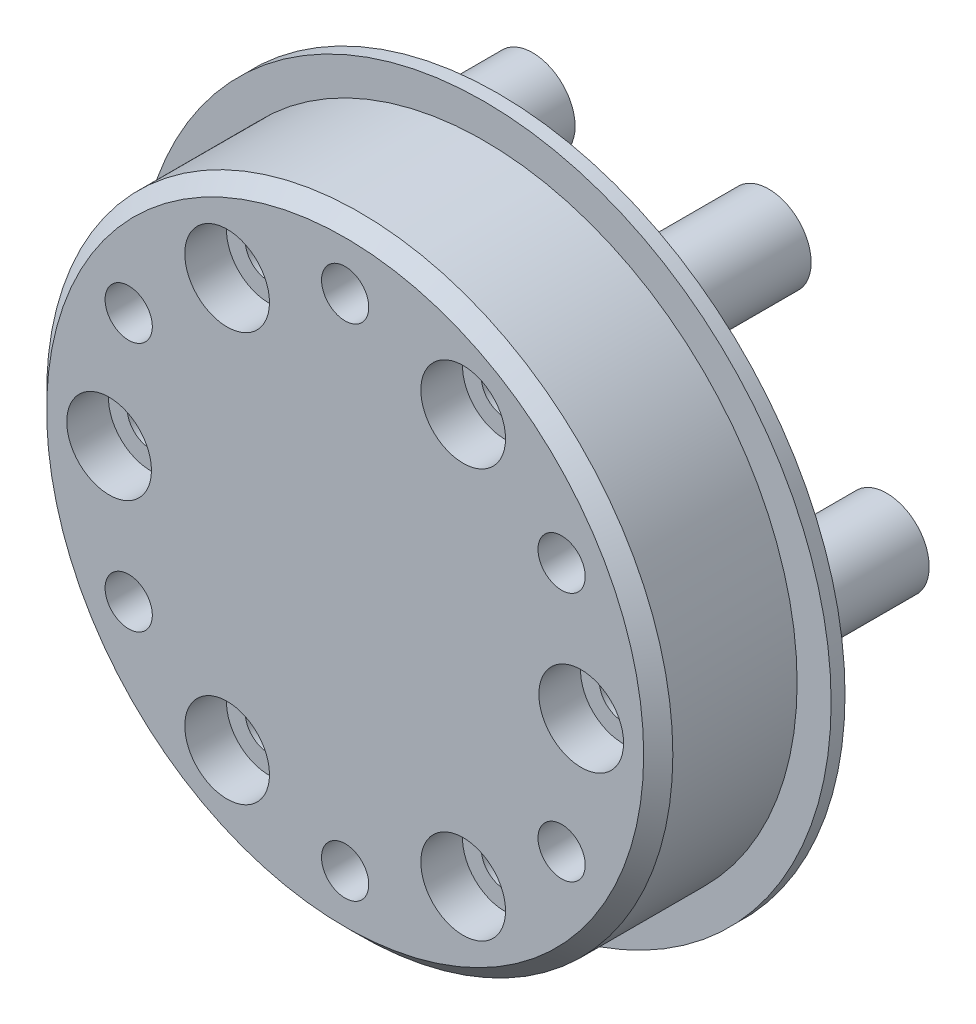
from build123d import *

# Parameters (mm, degrees)
SKETCH_1_W                   = 25
SKETCH_1_H                   = 1
SKETCH_2_R                   = 22.55
EXTRUDE_1_DEPTH              = 10
HOLE_WIZARD_M3_1_D           = 3.4
HOLE_WIZARD_M3_1_DEPTH       = 11
HOLE_WIZARD_M3_1_CBORE_D     = 4.5
HOLE_WIZARD_M3_1_CBORE_DEPTH = 6
HOLE_WIZARD_1_D              = 8
HOLE_WIZARD_1_DEPTH          = 5
HOLE_WIZARD_1_CBORE_D        = 10.16
HOLE_WIZARD_1_CBORE_DEPTH    = 3
HOLE_WIZARD_M3_2_D           = 3.4
HOLE_WIZARD_M3_2_DEPTH       = 22
HOLE_WIZARD_M3_2_CBORE_D     = 6.1
HOLE_WIZARD_M3_2_CBORE_DEPTH = 3
CHAMFER_1_SIZE               = 1.05


with BuildPart() as part:
    # 草图1 → 旋转1 (revolve)
    with BuildSketch(Plane(origin=(0, 0, 0), x_dir=(1, 0, 0), z_dir=(0, 1, 0))):
        with Locations((12.5, 10.5)):
            Rectangle(SKETCH_1_W, SKETCH_1_H)
    revolve(axis=Axis((0, 0, -11), (0, 0, 1)))

    # 草图2 → 凸台-拉伸1 (add)
    with BuildSketch(Plane.XY.offset(-10)):
        Circle(SKETCH_2_R)
    extrude(amount=EXTRUDE_1_DEPTH)

    # 草图3 → 旋转2 (revolve)
    with BuildSketch(Plane(origin=(0, -14.722431864, 0), x_dir=(1, 0, 0), z_dir=(0, 1, 0))):
        Polygon((11.56, 22), (8.5, 22), (8.5, 11), (12.5, 11), (12.5, 12.5), (11.56, 12.5), align=None)
    revolve(axis=Axis((8.5, -14.722431864, -22), (0, 0, 1)))

    # 草图4 → 旋转3 (revolve)
    with BuildSketch(Plane(origin=(0, -14.722431864, 0), x_dir=(1, 0, 0), z_dir=(0, 1, 0))):
        Polygon((-5.44, 22), (-8.5, 22), (-8.5, 11), (-4.5, 11), (-4.5, 12.5), (-5.44, 12.5), align=None)
    revolve(axis=Axis((-8.5, -14.722431864, -22), (0, 0, 1)))

    # 草图5 → 旋转4 (revolve)
    with BuildSketch(Plane(origin=(0, 0, 0), x_dir=(1, 0, 0), z_dir=(0, 1, 0))):
        Polygon((-13.94, 22), (-17, 22), (-17, 11), (-13, 11), (-13, 12.5), (-13.94, 12.5), align=None)
    revolve(axis=Axis((-17, 0, -22), (0, 0, 1)))

    # 草图6 → 旋转5 (revolve)
    with BuildSketch(Plane(origin=(0, 14.722431864, 0), x_dir=(1, 0, 0), z_dir=(0, 1, 0))):
        Polygon((-5.44, 22), (-8.5, 22), (-8.5, 11), (-4.5, 11), (-4.5, 12.5), (-5.44, 12.5), align=None)
    revolve(axis=Axis((-8.5, 14.722431864, -22), (0, 0, 1)))

    # 草图7 → 旋转6 (revolve)
    with BuildSketch(Plane(origin=(0, 14.722431864, 0), x_dir=(1, 0, 0), z_dir=(0, 1, 0))):
        Polygon((11.56, 22), (8.5, 22), (8.5, 11), (12.5, 11), (12.5, 12.5), (11.56, 12.5), align=None)
    revolve(axis=Axis((8.5, 14.722431864, -22), (0, 0, 1)))

    # 草图8 → 旋转7 (revolve)
    with BuildSketch(Plane(origin=(0, 0, 0), x_dir=(1, 0, 0), z_dir=(0, 1, 0))):
        Polygon((20.06, 22), (17, 22), (17, 11), (21, 11), (21, 12.5), (20.06, 12.5), align=None)
    revolve(axis=Axis((17, 0, -22), (0, 0, 1)))

    # M3 六角头机械螺钉的柱形沉头孔1
    with Locations(Plane(origin=(0, 0, -11), x_dir=(-1, 0, 0), z_dir=(0, 0, -1))):
        with Locations((15.588457268, 9), (0, 18), (-15.588457268, 9), (-15.588457268, -9), (0, -18), (15.588457268, -9)):
            CounterBoreHole(HOLE_WIZARD_M3_1_D / 2, HOLE_WIZARD_M3_1_CBORE_D / 2, HOLE_WIZARD_M3_1_CBORE_DEPTH, depth=HOLE_WIZARD_M3_1_DEPTH)

    # 孔1
    with Locations(Plane(origin=(0, 0, -11), x_dir=(-1, 0, 0), z_dir=(0, 0, -1))):
        with Locations((0, 0)):
            CounterBoreHole(HOLE_WIZARD_1_D / 2, HOLE_WIZARD_1_CBORE_D / 2, HOLE_WIZARD_1_CBORE_DEPTH, depth=HOLE_WIZARD_1_DEPTH)

    # M3 六角头机械螺钉的柱形沉头孔2
    with Locations(Plane.XY):
        with Locations((8.5, -14.722431864), (-8.5, -14.722431864), (-17, 0), (-8.5, 14.722431864), (8.5, 14.722431864), (17, 0)):
            CounterBoreHole(HOLE_WIZARD_M3_2_D / 2, HOLE_WIZARD_M3_2_CBORE_D / 2, HOLE_WIZARD_M3_2_CBORE_DEPTH, depth=HOLE_WIZARD_M3_2_DEPTH)

    # 倒角1
    chamfer_1_edges = [part.edges().sort_by_distance(p)[0] for p in [
        (-22.55, 0, 0),
    ]]
    chamfer(chamfer_1_edges, length=CHAMFER_1_SIZE)


solid = part.part
